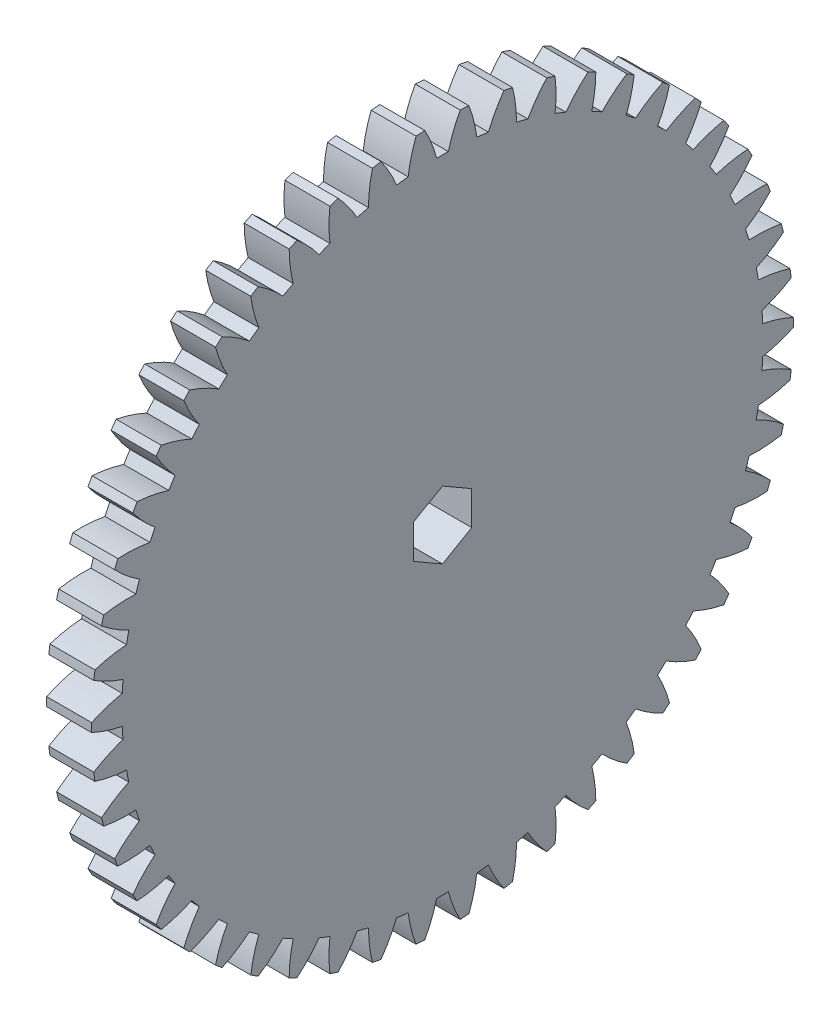
from build123d import *

# Parameters (mm, degrees)
BASPROSKE_W         = 5
BASPROSKE_H         = 39
TOOTHCUT_DEPTH      = 56.380501984
TEETHCUTS_COUNT     = 50
TEETHCUTS_ANGLE     = 352.8
BORE_DEPTH          = 50.0000508
BOSS_EXTRUDE1_DEPTH = 6


with BuildPart() as part:
    # BasProSke → Base-Revolve (revolve)
    with BuildSketch(Plane(origin=(0, 0, 0), x_dir=(1, 0, 0), z_dir=(0, 1, 0)), mode=Mode.PRIVATE) as base_revolve_sk:
        with Locations((2.5, 19.5)):
            Rectangle(BASPROSKE_W, BASPROSKE_H)
    revolve(base_revolve_sk.sketch.rotate(Axis((-10, 0, 0), (1, 0, 0)), 180), axis=Axis((-10, 0, 0), (1, 0, 0)))

    # TooCutSke → ToothCut (cut, through all)
    with BuildSketch(Plane(origin=(0, 0, 0), x_dir=(0, 0, -1), z_dir=(1, 0, 0))):
        with BuildLine():
            ThreePointArc((0.649974317, 35.618069984), (0, 35.624), (-0.649974317, 35.618069984))
            ThreePointArc((-0.649974317, 35.618069984), (-1.213667282, 37.336773563), (-1.980135572, 38.975131921))
            ThreePointArc((-1.980135572, 38.975131921), (0, 39.0254), (1.980135572, 38.975131921))
            ThreePointArc((1.980135572, 38.975131921), (1.213667282, 37.336773563), (0.649974317, 35.618069984))
        make_face()
    toothcut = extrude(amount=TOOTHCUT_DEPTH, mode=Mode.SUBTRACT)

    # TeethCuts: ToothCut ×50 about axis
    teethcuts_axis = Axis((-10, 0, 0), (1, 0, 0))
    for i in range(1, TEETHCUTS_COUNT):
        add(toothcut.rotate(teethcuts_axis, i * TEETHCUTS_ANGLE / (TEETHCUTS_COUNT - 1)), mode=Mode.SUBTRACT)

    # BorSke → Bore (cut, symmetric)
    with BuildSketch(Plane(origin=(0, 0, 0), x_dir=(0, 0, -1), z_dir=(1, 0, 0))):
        Polygon((0, -3.75), (3.247595264, -1.875), (3.247595264, 1.875), (0, 3.75), (-3.247595264, 1.875), (-3.247595264, -1.875), align=None)
    extrude(amount=BORE_DEPTH, both=True, mode=Mode.SUBTRACT)

    # Sketch1 → Boss-Extrude1 (add)
    with BuildSketch(Plane.ZY):
        with BuildLine():
            ThreePointArc((0.186825145, -8.9980607), (1.087459567, -7.388027907), (0.875696034, -5.555405697))
            ThreePointArc((0.875696034, -5.555405697), (1.737911579, -5.348741847), (2.556932571, -5.009138831))
            ThreePointArc((2.556932571, -5.009138831), (3.462800583, -6.616232824), (5.137782668, -7.389397083))
            ThreePointArc((5.137782668, -7.389397083), (5.290067274, -7.281152947), (5.440072096, -7.169770958))
            ThreePointArc((5.440072096, -7.169770958), (5.222347117, -5.337847436), (3.973838512, -3.979696405))
            ThreePointArc((3.973838512, -3.979696405), (4.549911578, -3.305704257), (5.012899835, -2.549551185))
            ThreePointArc((5.012899835, -2.549551185), (6.690388599, -3.317261679), (8.499932121, -2.958234937))
            ThreePointArc((8.499932121, -2.958234937), (8.559508648, -2.781152945), (8.615396408, -2.602872401))
            ThreePointArc((8.615396408, -2.602872401), (7.36247557, -1.248790671), (5.554109745, -0.883878352))
            ThreePointArc((5.554109745, -0.883878352), (5.624, 3e-09), (5.554109744, 0.883878357))
            ThreePointArc((5.554109744, 0.883878357), (7.362475569, 1.248790678), (8.615396405, 2.602872409))
            ThreePointArc((8.615396405, 2.602872409), (8.559508645, 2.781152953), (8.499932118, 2.958234945))
            ThreePointArc((8.499932118, 2.958234945), (6.690388596, 3.317261685), (5.012899832, 2.54955119))
            ThreePointArc((5.012899832, 2.54955119), (4.549911575, 3.305704261), (3.973838508, 3.979696409))
            ThreePointArc((3.973838508, 3.979696409), (5.222347112, 5.33784744), (5.44007209, 7.169770963))
            ThreePointArc((5.44007209, 7.169770963), (5.290067267, 7.281152952), (5.137782661, 7.389397088))
            ThreePointArc((5.137782661, 7.389397088), (3.462800577, 6.616232827), (2.556932566, 5.009138833))
            ThreePointArc((2.556932566, 5.009138833), (1.737911574, 5.348741848), (0.875696028, 5.555405698))
            ThreePointArc((0.875696028, 5.555405698), (1.08745956, 7.388027908), (0.186825137, 8.9980607))
            ThreePointArc((0.186825137, 8.9980607), (-4e-09, 9), (-0.186825145, 8.9980607))
            ThreePointArc((-0.186825145, 8.9980607), (-1.087459567, 7.388027907), (-0.875696034, 5.555405697))
            ThreePointArc((-0.875696034, 5.555405697), (-1.737911579, 5.348741847), (-2.556932571, 5.009138831))
            ThreePointArc((-2.556932571, 5.009138831), (-3.462800583, 6.616232824), (-5.137782668, 7.389397083))
            ThreePointArc((-5.137782668, 7.389397083), (-5.290067274, 7.281152947), (-5.440072096, 7.169770958))
            ThreePointArc((-5.440072096, 7.169770958), (-5.222347117, 5.337847436), (-3.973838512, 3.979696405))
            ThreePointArc((-3.973838512, 3.979696405), (-4.549911578, 3.305704257), (-5.012899835, 2.549551185))
            ThreePointArc((-5.012899835, 2.549551185), (-6.690388599, 3.317261679), (-8.499932121, 2.958234937))
            ThreePointArc((-8.499932121, 2.958234937), (-8.559508648, 2.781152945), (-8.615396408, 2.602872401))
            ThreePointArc((-8.615396408, 2.602872401), (-7.36247557, 1.248790671), (-5.554109745, 0.883878352))
            ThreePointArc((-5.554109745, 0.883878352), (-5.624, -3e-09), (-5.554109744, -0.883878357))
            ThreePointArc((-5.554109744, -0.883878357), (-7.362475569, -1.248790678), (-8.615396405, -2.602872409))
            ThreePointArc((-8.615396405, -2.602872409), (-8.559508645, -2.781152953), (-8.499932118, -2.958234945))
            ThreePointArc((-8.499932118, -2.958234945), (-6.690388596, -3.317261685), (-5.012899832, -2.54955119))
            ThreePointArc((-5.012899832, -2.54955119), (-4.549911575, -3.305704261), (-3.973838508, -3.979696409))
            ThreePointArc((-3.973838508, -3.979696409), (-5.222347112, -5.33784744), (-5.44007209, -7.169770963))
            ThreePointArc((-5.44007209, -7.169770963), (-5.290067267, -7.281152952), (-5.137782661, -7.389397088))
            ThreePointArc((-5.137782661, -7.389397088), (-3.462800577, -6.616232827), (-2.556932566, -5.009138833))
            ThreePointArc((-2.556932566, -5.009138833), (-1.737911574, -5.348741848), (-0.875696028, -5.555405698))
            ThreePointArc((-0.875696028, -5.555405698), (-1.08745956, -7.388027908), (-0.186825137, -8.9980607))
            ThreePointArc((-0.186825137, -8.9980607), (4e-09, -9), (0.186825145, -8.9980607))
        make_face()
        Polygon((3.247595264, -1.875), (3.247595264, 1.875), (0, 3.75), (-3.247595264, 1.875), (-3.247595264, -1.875), (0, -3.75), align=None, mode=Mode.SUBTRACT)
    extrude(amount=BOSS_EXTRUDE1_DEPTH)


solid = part.part
